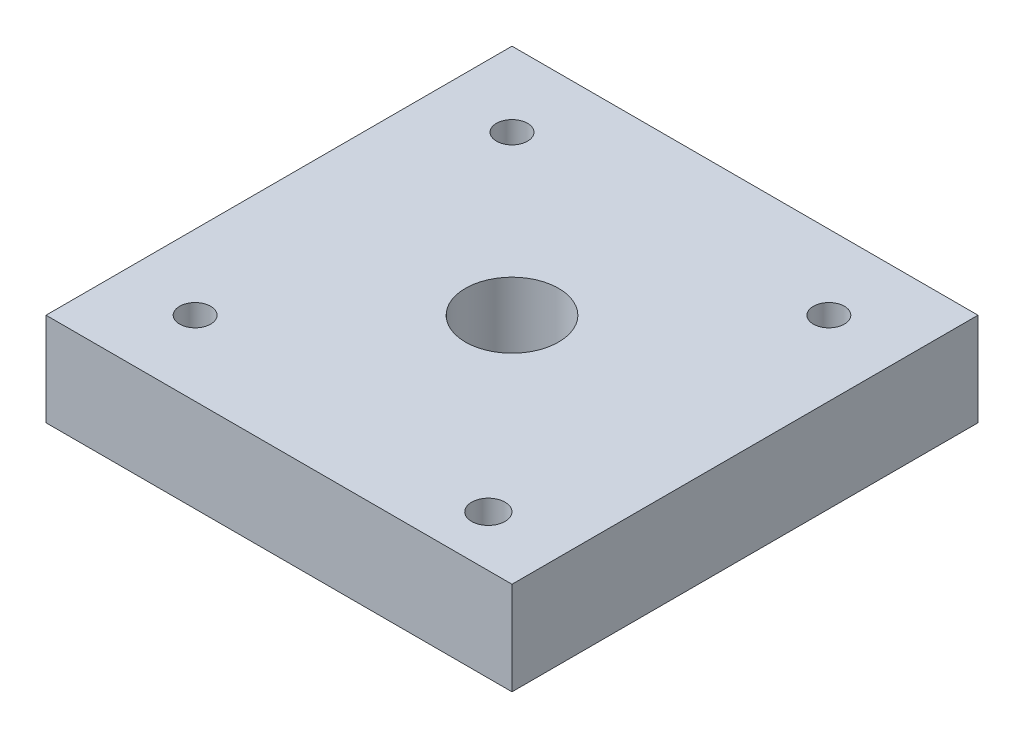
from build123d import *

# Parameters (mm, degrees)
SKETCH1_W           = 50
SKETCH1_H           = 50
SKETCH1_R           = 5
SKETCH1_R_2         = 1.666
SKETCH1_R_3         = 1.793902259
BOSS_EXTRUDE3_DEPTH = 10


with BuildPart() as part:
    # Sketch1 → Boss-Extrude3 (new body)
    with BuildSketch(Plane(origin=(0, 0, 0), x_dir=(1, 0, 0), z_dir=(0, 1, 0))):
        Rectangle(SKETCH1_W, SKETCH1_H)
        Circle(SKETCH1_R, mode=Mode.SUBTRACT)
        with Locations((-17, 17)):
            Circle(SKETCH1_R_2, mode=Mode.SUBTRACT)
        with Locations((17, 17)):
            Circle(SKETCH1_R_2, mode=Mode.SUBTRACT)
        with Locations((-17, -17)):
            Circle(SKETCH1_R_2, mode=Mode.SUBTRACT)
        with Locations((17, -19.536960904)):
            Circle(SKETCH1_R_3, mode=Mode.SUBTRACT)
    extrude(amount=BOSS_EXTRUDE3_DEPTH)


solid = part.part
